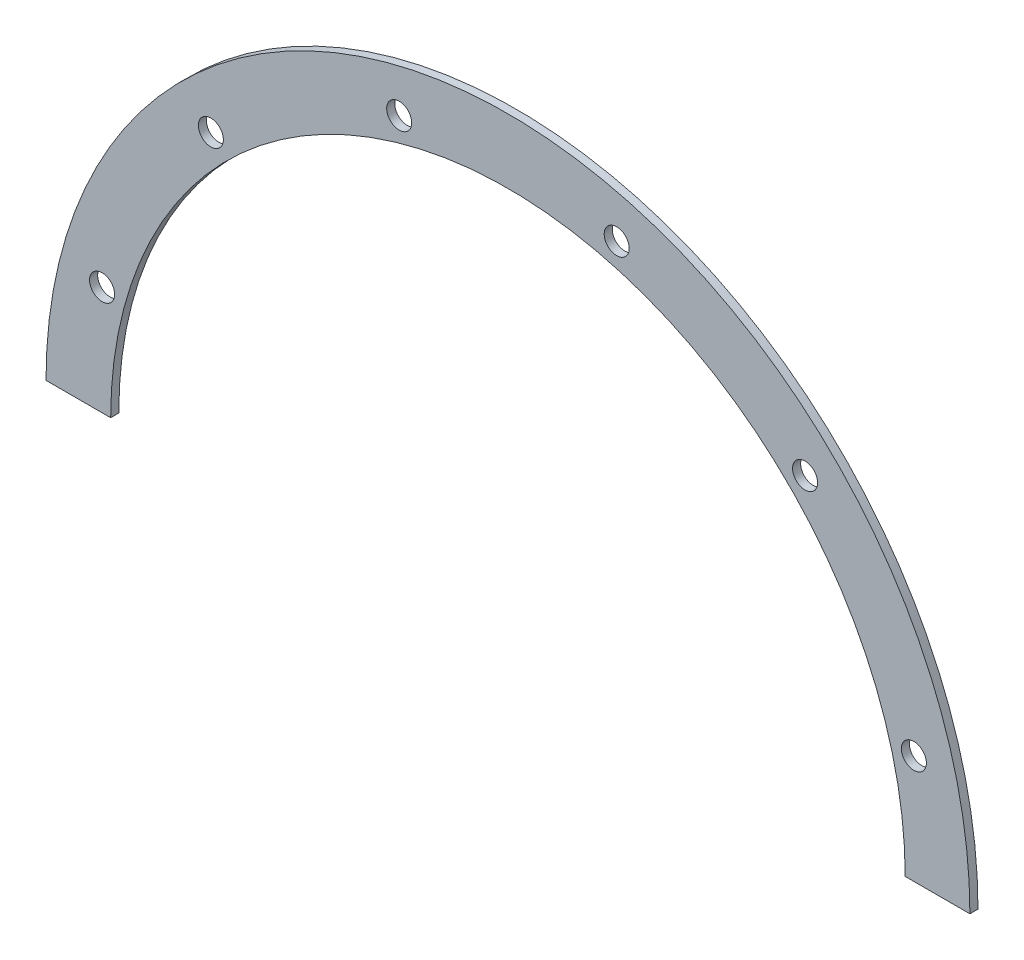
from build123d import *

# Parameters (mm, degrees)
BOSS_EXTRUDE1_DEPTH   = 1.5875
F_8_CLEARANCE_HOLE1_D = 4.9149
CIRPATTERN1_COUNT     = 6
CIRPATTERN1_ANGLE     = 150


with BuildPart() as part:
    # Sketch1 → Boss-Extrude1 (new body)
    with BuildSketch(Plane.XY):
        with BuildLine():
            Line((-90.7, 0), (-78, 0))
            ThreePointArc((-78, 0), (0, 78), (78, 0))
            Line((78, 0), (90.7, 0))
            ThreePointArc((90.7, 0), (0, 90.7), (-90.7, 0))
        make_face()
    extrude(amount=BOSS_EXTRUDE1_DEPTH)

    # #8 Clearance Hole1 (through all)
    with Locations(Plane.XY.offset(1.5875)):
        with Locations((79.688880669, 21.352571221)):
            f_8_clearance_hole1 = Hole(F_8_CLEARANCE_HOLE1_D / 2)

    # CirPattern1: #8 Clearance Hole1 ×6 about axis
    cirpattern1_axis = Axis((0, 0, 0), (0, 0, 1))
    for i in range(1, CIRPATTERN1_COUNT):
        add(f_8_clearance_hole1.rotate(cirpattern1_axis, i * CIRPATTERN1_ANGLE / (CIRPATTERN1_COUNT - 1)), mode=Mode.SUBTRACT)


solid = part.part
